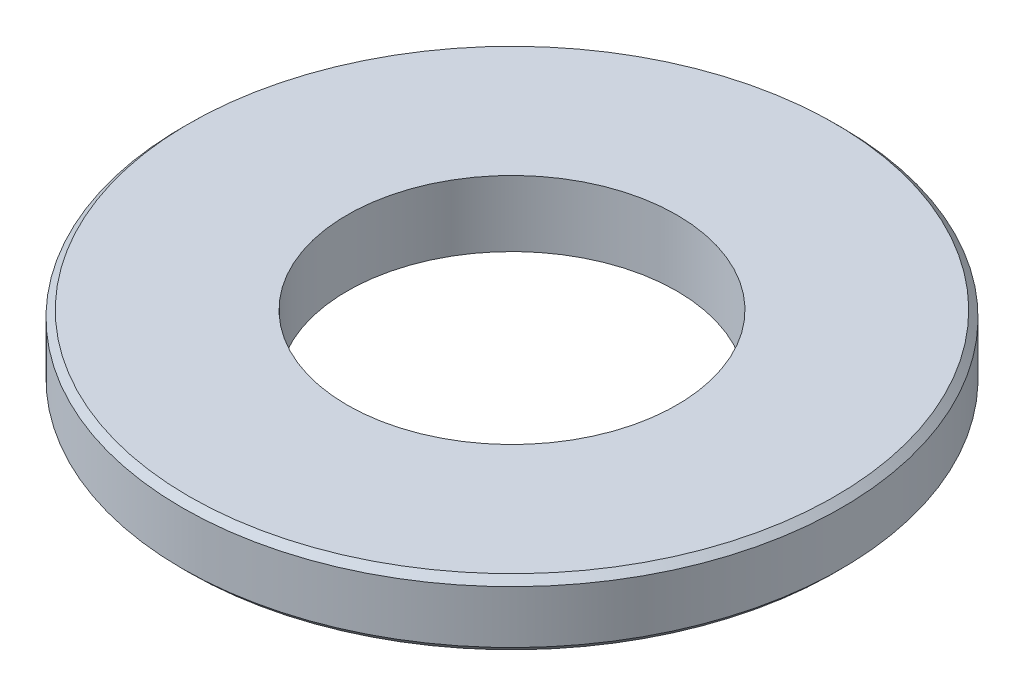
from build123d import *

# Parameters (mm, degrees)
SKETCH1_R           = 12.7
SKETCH1_R_2         = 6.35
BOSS_EXTRUDE1_DEPTH = 2.54
CHAMFER1_SIZE       = 0.254


with BuildPart() as part:
    # Sketch1 → Boss-Extrude1 (new body)
    with BuildSketch(Plane(origin=(0, 0, 0), x_dir=(1, 0, 0), z_dir=(0, 1, 0))):
        Circle(SKETCH1_R)
        Circle(SKETCH1_R_2, mode=Mode.SUBTRACT)
    extrude(amount=BOSS_EXTRUDE1_DEPTH)

    # Chamfer1
    chamfer1_edges = [part.edges().sort_by_distance(p)[0] for p in [
        (-12.7, 0, 0),
        (-12.7, 2.54, 0),
    ]]
    chamfer(chamfer1_edges, length=CHAMFER1_SIZE)


solid = part.part
